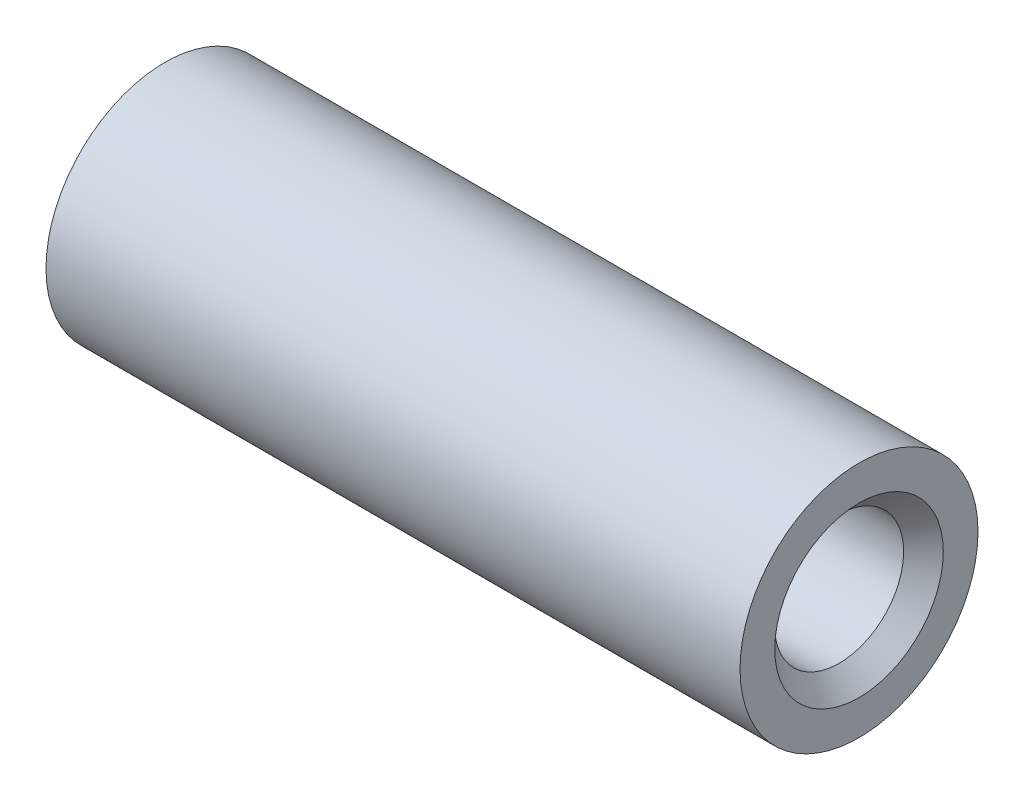
from build123d import *

# Parameters (mm, degrees)
SKETCH_1_R      = 6
SKETCH_1_R_2    = 3.25
EXTRUDE_1_DEPTH = 35
CHAMFER_1_SIZE  = 1


with BuildPart() as part:
    # Эскиз1 → Бобышка-Вытянуть1 (new body)
    with BuildSketch(Plane(origin=(0, 0, 0), x_dir=(0, 0, -1), z_dir=(1, 0, 0))):
        Circle(SKETCH_1_R)
        Circle(SKETCH_1_R_2, mode=Mode.SUBTRACT)
    extrude(amount=EXTRUDE_1_DEPTH)

    # Фаска1
    chamfer_1_edges = [part.edges().sort_by_distance(p)[0] for p in [
        (0, 0, 3.25),
        (35, 0, 3.25),
    ]]
    chamfer(chamfer_1_edges, length=CHAMFER_1_SIZE)


solid = part.part
